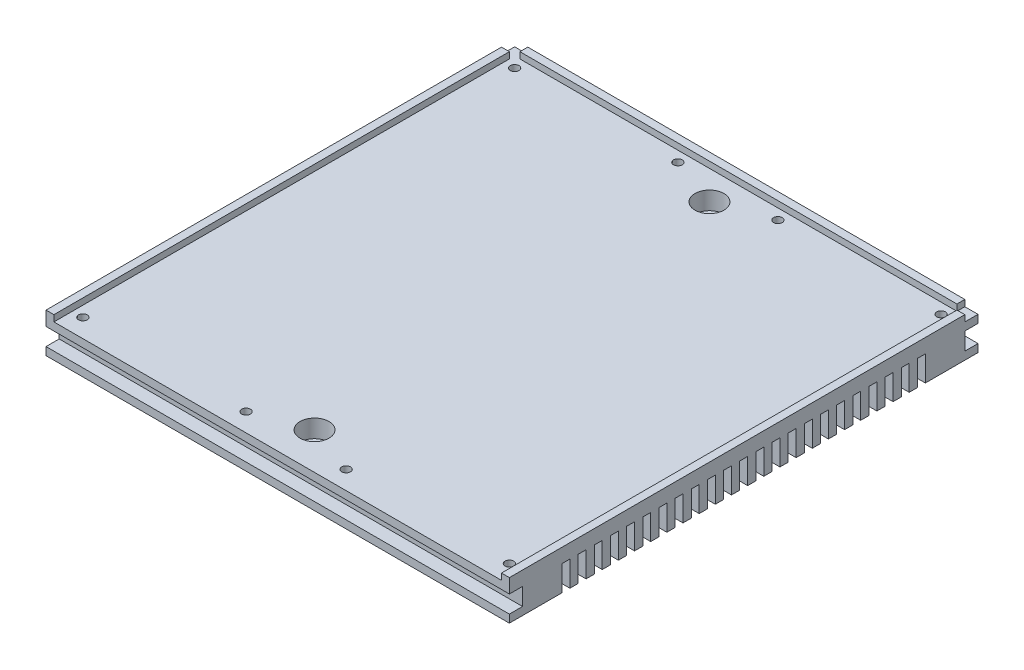
from build123d import *

# Parameters (mm, degrees)
SKETCH_1_W                = 176
SKETCH_1_H                = 178
EXTRUDE_1_DEPTH           = 12.6
EXTRUDE_3_DEPTH           = 2.4
SKETCH_8_W                = 5
SKETCH_8_H                = 5
CUT_EXTRUDE_4_DEPTH       = 2.4
HOLE_WIZARD_M4_1_D        = 3.3
HOLE_WIZARD_M4_1_DEPTH    = 5
HOLE_WIZARD_M4_1_TIP      = 0.991420021
SKETCH_14_W               = 5
SKETCH_14_H               = 6.6
CUT_EXTRUDE_6_DEPTH       = 177
SKETCH_15_W               = 3
SKETCH_15_H               = 9.6
CUT_EXTRUDE_7_DEPTH       = 177
PATTERN_LINEAR_3_COUNT    = 23
PATTERN_LINEAR_3_PITCH    = 6.136363636
HOLE_WIZARD_2_D           = 6.6
HOLE_WIZARD_2_CBORE_D     = 11
HOLE_WIZARD_2_CBORE_DEPTH = 6.8
MM_2_D                    = 4
MM_2_DEPTH                = 5
MM_2_TIP                  = 1.201721238
CUT_EXTRUDE_11_DEPTH      = 5


with BuildPart() as part:
    # 草图1 → 凸台-拉伸1 (new body)
    with BuildSketch(Plane(origin=(0, 12.6, 0), x_dir=(1, 0, 0), z_dir=(0, 1, 0))):
        with Locations((-15.748130707, -439.724508868)):
            Rectangle(SKETCH_1_W, SKETCH_1_H)
    extrude(amount=-EXTRUDE_1_DEPTH)

    # 草图7 → 凸台-拉伸3 (add)
    with BuildSketch(Plane(origin=(0, 12.6, 0), x_dir=(1, 0, 0), z_dir=(0, 1, 0))):
        Polygon((69.251869293, -528.724508868), (69.251869293, -353.724508868), (-100.748130707, -353.724508868), (-100.748130707, -528.724508868), (-103.748130707, -528.724508868), (-103.748130707, -350.724508868), (72.251869293, -350.724508868), (72.251869293, -528.724508868), align=None)
    extrude(amount=EXTRUDE_3_DEPTH)

    # 草图8 → 切除-拉伸4 (cut)
    with BuildSketch(Plane(origin=(0, 15, 0), x_dir=(1, 0, 0), z_dir=(0, 1, 0))):
        with Locations((-101.248130707, -353.224508868)):
            Rectangle(SKETCH_8_W, SKETCH_8_H)
        with Locations((69.751869293, -353.224508868)):
            Rectangle(SKETCH_8_W, SKETCH_8_H)
    extrude(amount=-CUT_EXTRUDE_4_DEPTH, mode=Mode.SUBTRACT)

    # M4 螺纹孔1
    with Locations(Plane(origin=(-96.748130707, 12.6, 357.724508868), x_dir=(0, 0, 1), z_dir=(0, 1, 0))):
        with Locations((0, 0), (0, 62), (164, 62), (164, 0), (164, 100), (164, 162), (0, 162), (0, 100)):
            Hole(HOLE_WIZARD_M4_1_D / 2, depth=HOLE_WIZARD_M4_1_DEPTH)
            with Locations((0, 0, -(HOLE_WIZARD_M4_1_DEPTH + HOLE_WIZARD_M4_1_TIP / 2))):  # 118° drill point
                Cone(0, HOLE_WIZARD_M4_1_D / 2, HOLE_WIZARD_M4_1_TIP, mode=Mode.SUBTRACT)

    # 草图14 → 切除-拉伸6 (cut, through all)
    with BuildSketch(Plane.ZY.offset(103.748130707)):
        with Locations((526.224508868, 6.3)):
            Rectangle(SKETCH_14_W, SKETCH_14_H)
        with Locations((353.224508868, 6.3)):
            Rectangle(SKETCH_14_W, SKETCH_14_H)
    extrude(amount=-CUT_EXTRUDE_6_DEPTH, mode=Mode.SUBTRACT)

    # 草图15 → 切除-拉伸7 (cut, through all)
    with BuildSketch(Plane.ZY.offset(103.748130707)):
        with Locations((507.224508868, 4.8)):
            Rectangle(SKETCH_15_W, SKETCH_15_H)
    cut_extrude_7 = extrude(amount=-CUT_EXTRUDE_7_DEPTH, mode=Mode.SUBTRACT)

    # 阵列(线性)3: 切除-拉伸7 ×23
    with Locations(*[(0, 0, -i * PATTERN_LINEAR_3_PITCH) for i in range(1, PATTERN_LINEAR_3_COUNT)]):
        add(cut_extrude_7, mode=Mode.SUBTRACT)

    # 打孔尺寸(%根据)内六角圆柱头螺钉的类型2 (through all)
    with Locations(Plane(origin=(-15.748130707, 12.6, 514.724508868), x_dir=(0, 0, 1), z_dir=(0, 1, 0))):
        with Locations((0, 0), (-150, 0)):
            CounterBoreHole(HOLE_WIZARD_2_D / 2, HOLE_WIZARD_2_CBORE_D / 2, HOLE_WIZARD_2_CBORE_DEPTH)

    # 大小mm 暗销孔2
    with Locations(Plane(origin=(-5.748130707, 0, 364.724508868), x_dir=(0, 0, -1), z_dir=(0, -1, 0))):
        with Locations((0, 0)):
            Hole(MM_2_D / 2, depth=MM_2_DEPTH)
            with Locations((0, 0, -(MM_2_DEPTH + MM_2_TIP / 2))):  # 118° drill point
                Cone(0, MM_2_D / 2, MM_2_TIP, mode=Mode.SUBTRACT)

    # 草图22 → 切除-拉伸11 (cut)
    with BuildSketch(Plane.XZ):
        with BuildLine():
            Line((-7.748130707, 513.724508868), (-7.748130707, 515.724508868))
            ThreePointArc((-7.748130707, 515.724508868), (-5.748130707, 517.724508868), (-3.748130707, 515.724508868))
            Line((-3.748130707, 515.724508868), (-3.748130707, 513.724508868))
            ThreePointArc((-3.748130707, 513.724508868), (-5.748130707, 511.724508868), (-7.748130707, 513.724508868))
        make_face()
    extrude(amount=-CUT_EXTRUDE_11_DEPTH, mode=Mode.SUBTRACT)


solid = part.part
